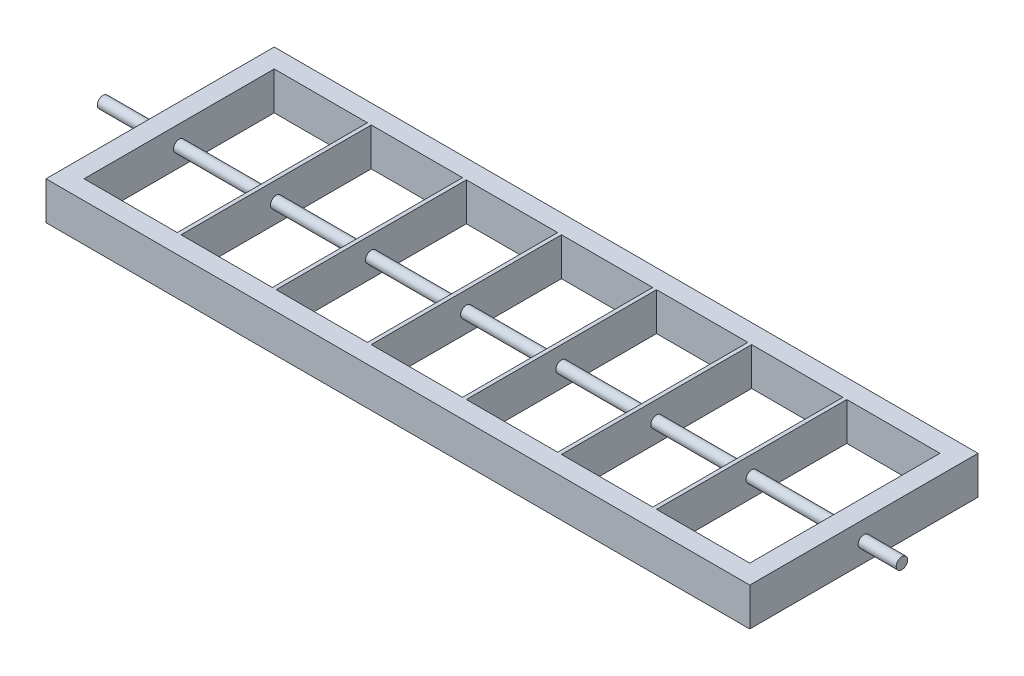
from build123d import *

# Parameters (mm, degrees)
SKETCH1_W                = 370
SKETCH1_H                = 120
SKETCH1_W_2              = 350
SKETCH1_H_2              = 100
BOSS_EXTRUDE1_DEPTH      = 20
SKETCH2_R                = 3
BOSS_EXTRUDE2_DEPTH      = 30
BOSS_EXTRUDE2_DEPTH_BACK = 390
SKETCH4_W                = 2
SKETCH4_H                = 20
BOSS_EXTRUDE3_DEPTH      = 100


with BuildPart() as part:
    # Sketch1 → Boss-Extrude1 (new body)
    with BuildSketch(Plane(origin=(0, 0, 0), x_dir=(1, 0, 0), z_dir=(0, 1, 0))):
        Rectangle(SKETCH1_W, SKETCH1_H)
        Rectangle(SKETCH1_W_2, SKETCH1_H_2, mode=Mode.SUBTRACT)
    extrude(amount=BOSS_EXTRUDE1_DEPTH)

    # Sketch2 → Boss-Extrude2 (add, two sides)
    with BuildSketch(Plane.ZY.offset(185)) as boss_extrude2_sk:
        with Locations((0, 10)):
            Circle(SKETCH2_R)
    extrude(amount=BOSS_EXTRUDE2_DEPTH)
    extrude(boss_extrude2_sk.sketch, amount=-BOSS_EXTRUDE2_DEPTH_BACK)

    # Sketch4 → Boss-Extrude3 (add)
    with BuildSketch(Plane(origin=(0, 0, 50), x_dir=(-1, 0, 0), z_dir=(0, 0, -1))):
        with Locations((-125, 10)):
            Rectangle(SKETCH4_W, SKETCH4_H)
        with Locations((-75, 10)):
            Rectangle(SKETCH4_W, SKETCH4_H)
        with Locations((-25, 10)):
            Rectangle(SKETCH4_W, SKETCH4_H)
        with Locations((25, 10)):
            Rectangle(SKETCH4_W, SKETCH4_H)
        with Locations((75, 10)):
            Rectangle(SKETCH4_W, SKETCH4_H)
        with Locations((125, 10)):
            Rectangle(SKETCH4_W, SKETCH4_H)
    extrude(amount=BOSS_EXTRUDE3_DEPTH)


solid = part.part
